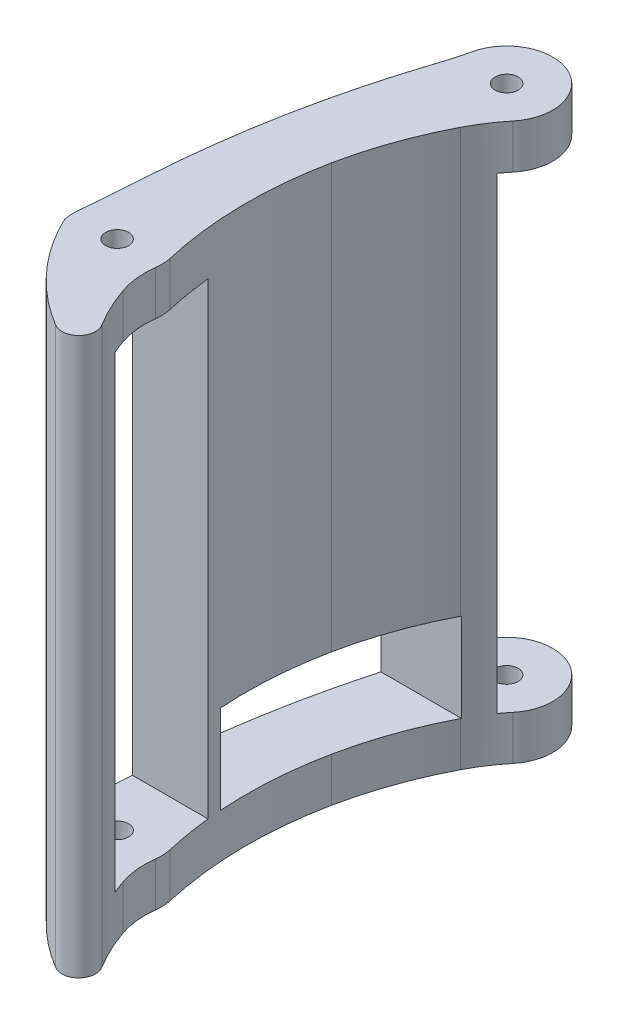
from build123d import *

# Parameters (mm, degrees)
SKETCH1_R           = 1.651
BOSS_EXTRUDE1_DEPTH = 79.756
SKETCH3_R           = 6.858
CUT_EXTRUDE2_DEPTH  = 67.056
CUT_EXTRUDE3_DEPTH  = 12.7


with BuildPart() as part:
    # Sketch1 → Boss-Extrude1 (new body)
    with BuildSketch(Plane(origin=(0, 0, 0), x_dir=(1, 0, 0), z_dir=(0, 1, 0))):
        with BuildLine():
            ThreePointArc((-46.347101967, -12.820550524), (-45.953093742, -7.978326418), (-45.607903753, -3.132377527))
            ThreePointArc((-45.607903753, -3.132377527), (-43.324155634, 14.457824244), (-38.846810395, 31.621276211))
            ThreePointArc((-38.846810395, 31.621276211), (-38.301804917, 33.429574735), (-37.849619012, 35.263287481))
            ThreePointArc((-37.849619012, 35.263287481), (-28.512474187, 39.785530688), (-26.300260653, 29.649502453))
            ThreePointArc((-26.300260653, 29.649502453), (-27.908796698, 27.470225182), (-29.278925969, 25.133692836))
            ThreePointArc((-29.278925969, 25.133692836), (-32.172639115, 18.448511751), (-34.117731608, 11.428409395))
            ThreePointArc((-34.117731608, 11.428409395), (-35.22666999, -0.274420306), (-33.831690761, -11.946609488))
            ThreePointArc((-33.831690761, -11.946609488), (-33.67793303, -13.064327384), (-33.724408967, -14.191613825))
            ThreePointArc((-33.724408967, -14.191613825), (-33.760843575, -16.790093108), (-33.198139816, -19.327175397))
            ThreePointArc((-33.198139816, -19.327175397), (-31.977523501, -22.310967081), (-30.442888304, -25.146070573))
            ThreePointArc((-30.442888304, -25.146070573), (-30.782899932, -28.090653785), (-33.723620439, -28.462596122))
            ThreePointArc((-33.723620439, -28.462596122), (-40.997268986, -22.504520927), (-46.230736135, -14.693282563))
            ThreePointArc((-46.230736135, -14.693282563), (-46.358471746, -13.761238335), (-46.347101967, -12.820550524))
        make_face()
        with Locations((-31.399492492, 33.846007028)):
            Circle(SKETCH1_R, mode=Mode.SUBTRACT)
        with Locations((-40.020695033, -13.367428306)):
            Circle(SKETCH1_R, mode=Mode.SUBTRACT)
    extrude(amount=BOSS_EXTRUDE1_DEPTH)

    # Sketch3 → Cut-Extrude2 (cut)
    with BuildSketch(Plane(origin=(0, 6.35, 0), x_dir=(-1, 0, 0), z_dir=(0, 1, 0))):
        with Locations((31.399492492, -33.846007028)):
            Circle(SKETCH3_R)
        with BuildLine():
            Line((33.192444355, 5.435760509), (47.285899843, 5.435760509))
            Line((47.285899843, 5.435760509), (46.632941201, 11.116111886))
            ThreePointArc((46.632941201, 11.116111886), (46.99317865, 13.785396267), (46.316644417, 16.392531007))
            Line((46.316644417, 16.392531007), (44.60108667, 21.165715919))
            Line((44.60108667, 21.165715919), (30.194900336, 21.165715919))
            Line((30.194900336, 21.165715919), (33.055086417, 12.847311389))
            ThreePointArc((33.055086417, 12.847311389), (33.189965557, 11.90751056), (33.451045025, 10.994682267))
            Line((33.451045025, 10.994682267), (33.192444355, 5.435760509))
        make_face()
    extrude(amount=CUT_EXTRUDE2_DEPTH, mode=Mode.SUBTRACT)

    # Sketch4 → Cut-Extrude3 (cut)
    with BuildSketch(Plane(origin=(0, 6.35, 0), x_dir=(-1, 0, 0), z_dir=(0, 1, 0))):
        Polygon((28.455486036, -25.206679833), (46.063076484, -25.206679833), (52.862178533, 3.477031937), (29.73031767, 3.477031937), align=None)
    extrude(amount=CUT_EXTRUDE3_DEPTH, mode=Mode.SUBTRACT)


solid = part.part
